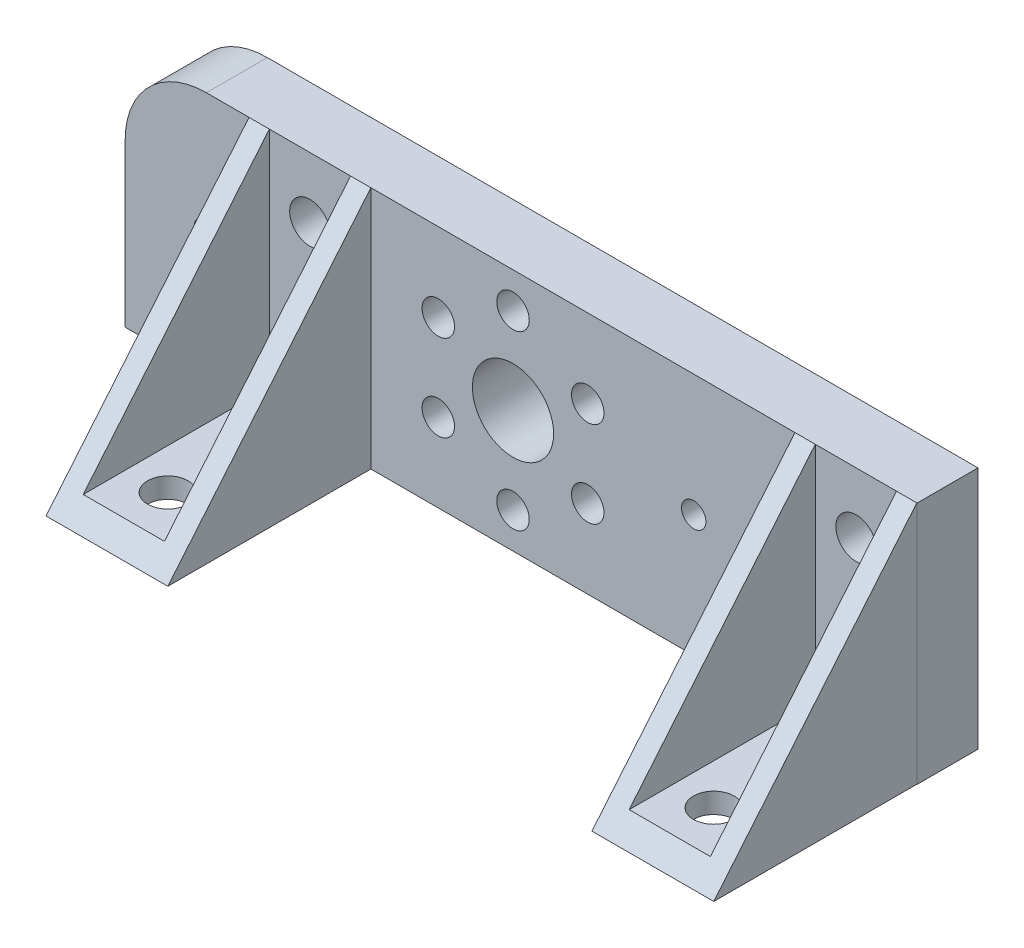
from build123d import *

# Parameters (mm, degrees)
SKETCH1_R           = 2
SKETCH1_R_2         = 0.6
SKETCH1_R_3         = 1
BOSS_EXTRUDE1_DEPTH = 3
SKETCH3_R           = 0.8
CUT_EXTRUDE1_DEPTH  = 3
CIRPATTERN1_COUNT   = 6
BOSS_EXTRUDE3_DEPTH = 10
CUT_EXTRUDE2_DEPTH  = 45
SKETCH7_R           = 1
CUT_EXTRUDE3_DEPTH  = 10
LPATTERN1_COUNT     = 2
LPATTERN1_PITCH     = 26.886757186


with BuildPart() as part:
    # Sketch1 → Boss-Extrude1 (new body)
    with BuildSketch(Plane.XY):
        with BuildLine():
            Line((-23.1, -6), (15.9, -6))
            Line((15.9, -6), (15.9, 6))
            Line((15.9, 6), (-19.1, 6))
            ThreePointArc((-19.1, 6), (-21.928427125, 4.828427125), (-23.1, 2))
            Line((-23.1, 2), (-23.1, -6))
        make_face()
        with Locations((-4, 0)):
            Circle(SKETCH1_R, mode=Mode.SUBTRACT)
        with Locations((4.9, 0)):
            Circle(SKETCH1_R_2, mode=Mode.SUBTRACT)
        with Locations((-19.1, 0)):
            Circle(SKETCH1_R_2, mode=Mode.SUBTRACT)
        with Locations((12.9, 3)):
            Circle(SKETCH1_R_3, mode=Mode.SUBTRACT)
        with Locations((12.9, -3)):
            Circle(SKETCH1_R_3, mode=Mode.SUBTRACT)
        with Locations((-14, -3)):
            Circle(SKETCH1_R_3, mode=Mode.SUBTRACT)
        with Locations((-14, 3)):
            Circle(SKETCH1_R_3, mode=Mode.SUBTRACT)
    extrude(amount=BOSS_EXTRUDE1_DEPTH)

    # Sketch3 → Cut-Extrude1 (cut)
    with BuildSketch(Plane.XY.offset(3)):
        with Locations((-4, 4.25)):
            Circle(SKETCH3_R)
    cut_extrude1 = extrude(amount=-CUT_EXTRUDE1_DEPTH, mode=Mode.SUBTRACT)

    # CirPattern1: Cut-Extrude1 ×6 about axis
    cirpattern1_axis = Axis((-4, 0, 0), (0, 0, 1))
    for i in range(1, CIRPATTERN1_COUNT):
        add(cut_extrude1.rotate(cirpattern1_axis, i * 360 / CIRPATTERN1_COUNT), mode=Mode.SUBTRACT)

    # Sketch4 → Boss-Extrude3 (add)
    with BuildSketch(Plane.XY.offset(3)):
        Polygon((-17, 6), (-17, -6), (-11, -6), (-11, 6), (-12, 6), (-12, -5), (-16, -5), (-16, 6), align=None)
    boss_extrude3 = extrude(amount=BOSS_EXTRUDE3_DEPTH)

    # Sketch5 → Cut-Extrude2 (cut)
    with BuildSketch(Plane.ZY.offset(17)):
        Polygon((3, 6), (13, -6), (13, 6), align=None)
    cut_extrude2 = extrude(amount=-CUT_EXTRUDE2_DEPTH, mode=Mode.SUBTRACT)

    # Sketch7 → Cut-Extrude3 (cut)
    with BuildSketch(Plane(origin=(0, -5, 0), x_dir=(1, 0, 0), z_dir=(0, 1, 0))):
        with Locations((-14, -5)):
            Circle(SKETCH7_R)
        with Locations((-14, -10)):
            Circle(SKETCH7_R)
    cut_extrude3 = extrude(amount=-CUT_EXTRUDE3_DEPTH, mode=Mode.SUBTRACT)

    # LPattern1: Boss-Extrude3, Cut-Extrude2, Cut-Extrude3 ×2
    with Locations(*[(i * LPATTERN1_PITCH, 0, 0) for i in range(1, LPATTERN1_COUNT)]):
        add(boss_extrude3)
        add(cut_extrude2, mode=Mode.SUBTRACT)
        add(cut_extrude3, mode=Mode.SUBTRACT)


solid = part.part
